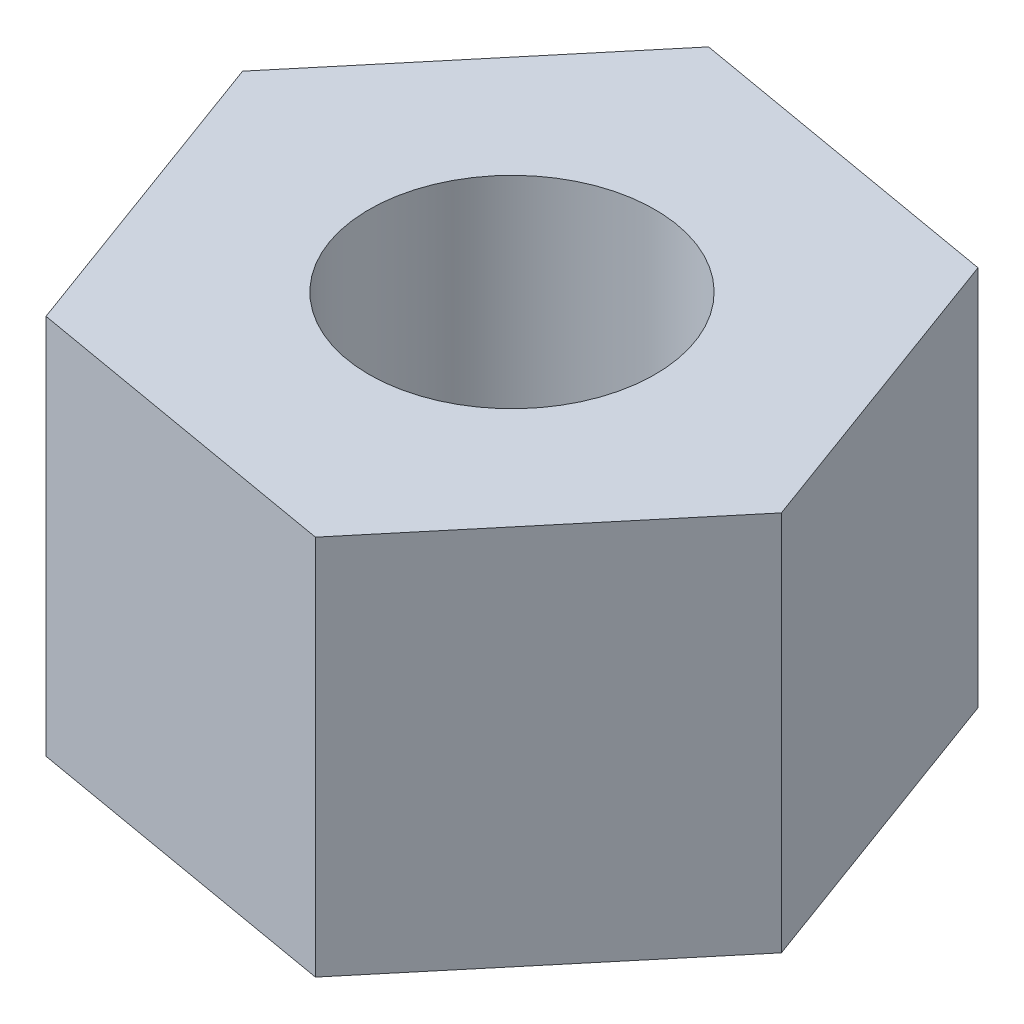
from build123d import *

# Parameters (mm, degrees)
BOSS_EXTRUDE1_DEPTH   = 1.5875
F_0_80_TAPPED_HOLE1_D = 1.19126


with BuildPart() as part:
    # Sketch1 → Boss-Extrude1 (new body)
    with BuildSketch(Plane(origin=(0, 0, 0), x_dir=(1, 0, 0), z_dir=(0, 1, 0))):
        Polygon((-0.474995971, 1.294059535), (-1.358186417, 0.23567119), (-0.883190446, -1.058388345), (0.474995971, -1.294059535), (1.358186417, -0.23567119), (0.883190446, 1.058388345), align=None)
    extrude(amount=BOSS_EXTRUDE1_DEPTH)

    # #0-80 Tapped Hole1 (through all)
    with Locations(Plane(origin=(0, 1.5875, 0), x_dir=(1, 0, 0), z_dir=(0, 1, 0))):
        with Locations((0, 0)):
            Hole(F_0_80_TAPPED_HOLE1_D / 2)


solid = part.part
